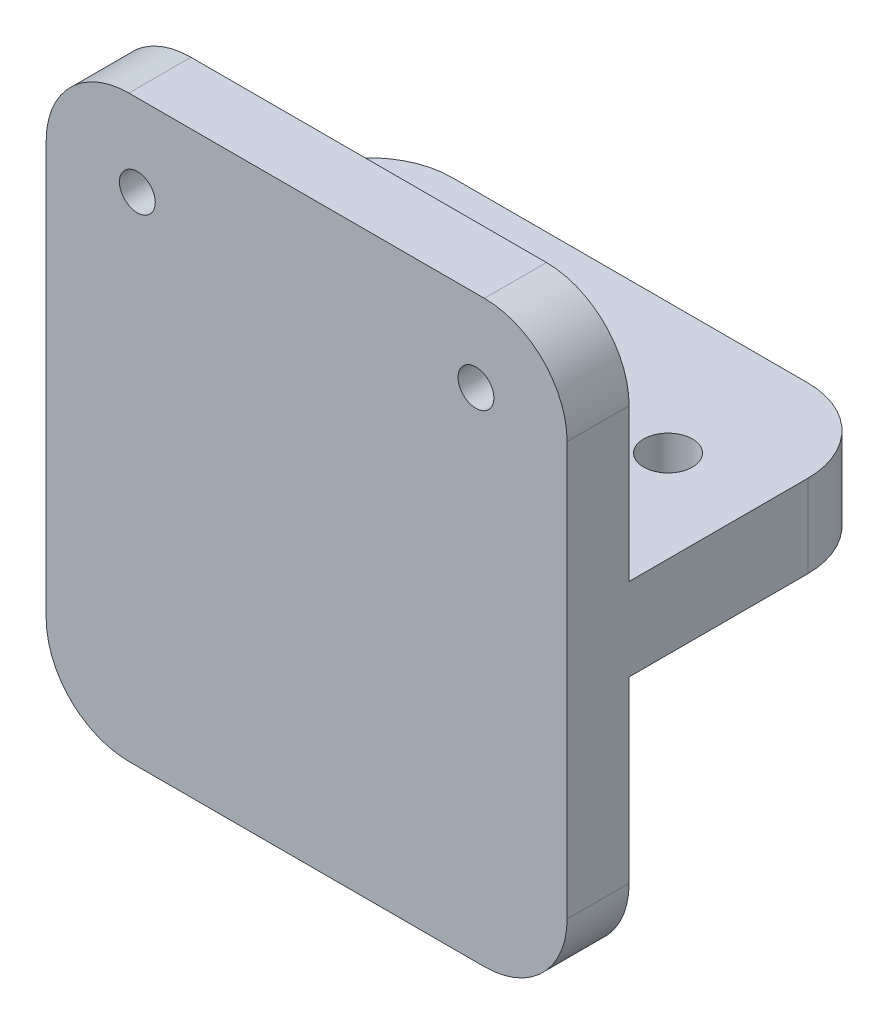
from build123d import *

# Parameters (mm, degrees)
SKETCH1_W           = 40
SKETCH1_H           = 44.45
SKETCH1_R           = 1.375
BOSS_EXTRUDE1_DEPTH = 4.7625
SKETCH2_W           = 40
SKETCH2_H           = 6.35
BOSS_EXTRUDE2_DEPTH = 20.066
SKETCH3_R           = 1.875
CUT_EXTRUDE1_DEPTH  = 27.416
FILLET1_R           = 6.35


with BuildPart() as part:
    # Sketch1 → Boss-Extrude1 (new body)
    with BuildSketch(Plane.XY):
        Rectangle(SKETCH1_W, SKETCH1_H)
        with Locations((-13, 15.958682008)):
            Circle(SKETCH1_R, mode=Mode.SUBTRACT)
        with Locations((13, 15.958682008)):
            Circle(SKETCH1_R, mode=Mode.SUBTRACT)
    extrude(amount=BOSS_EXTRUDE1_DEPTH)

    # Sketch2 → Boss-Extrude2 (add)
    with BuildSketch(Plane(origin=(0, 0, 0), x_dir=(-1, 0, 0), z_dir=(0, 0, -1))):
        with Locations((0, 1.016)):
            Rectangle(SKETCH2_W, SKETCH2_H)
    extrude(amount=BOSS_EXTRUDE2_DEPTH)

    # Sketch3 → Cut-Extrude1 (cut, through all)
    with BuildSketch(Plane(origin=(0, 4.191, 0), x_dir=(1, 0, 0), z_dir=(0, 1, 0))):
        with Locations((12.954, 10.033)):
            Circle(SKETCH3_R)
        with Locations((-12.954, 10.033)):
            Circle(SKETCH3_R)
    extrude(amount=-CUT_EXTRUDE1_DEPTH, mode=Mode.SUBTRACT)

    # Fillet1
    fillet1_edges = [part.edges().sort_by_distance(p)[0] for p in [
        (20, 1.016, -20.066),
        (-20, 1.016, -20.066),
        (20, -22.225, 2.38125),
        (-20, -22.225, 2.38125),
        (-20, 22.225, 2.38125),
        (20, 22.225, 2.38125),
    ]]
    fillet(fillet1_edges, radius=FILLET1_R)


solid = part.part
